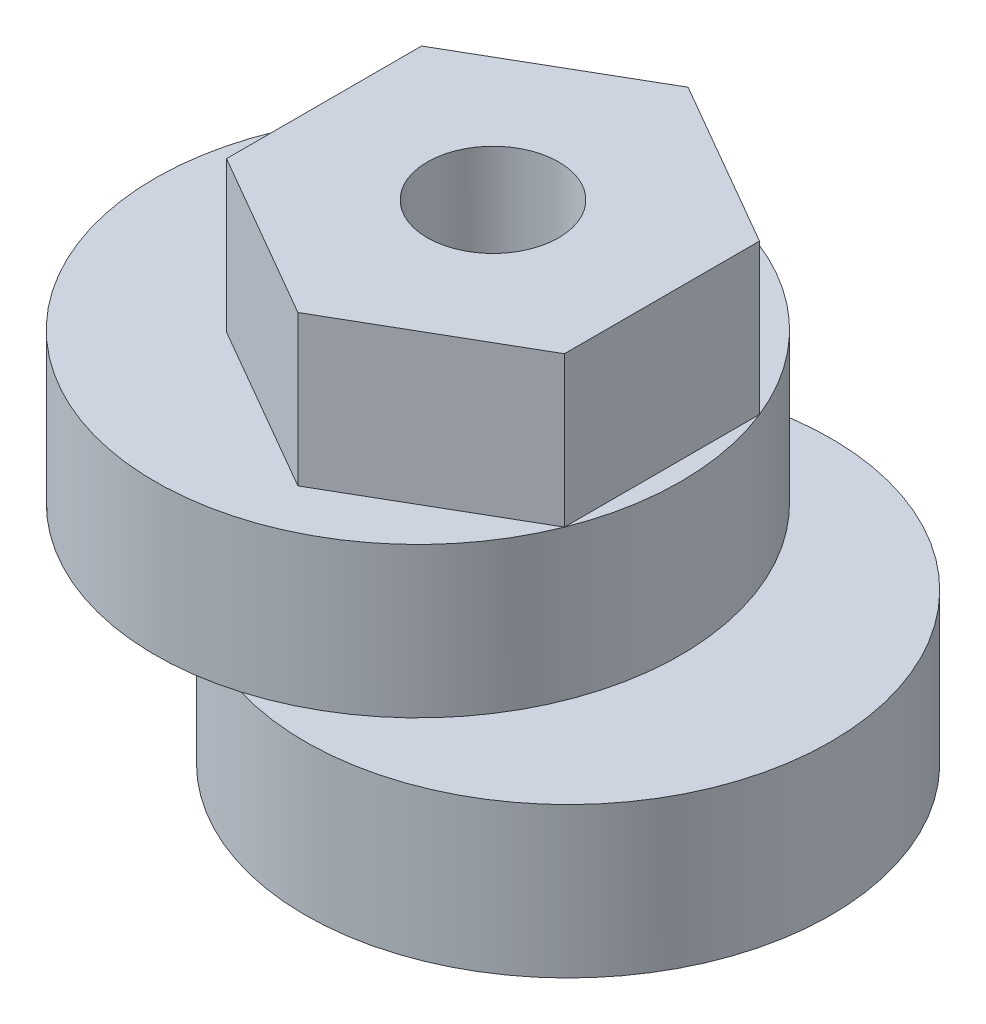
from build123d import *

# Parameters (mm, degrees)
SKETCH1_R           = 5
BOSS_EXTRUDE1_DEPTH = 2
SKETCH2_R           = 7
BOSS_EXTRUDE2_DEPTH = 4
SKETCH4_R           = 7
BOSS_EXTRUDE4_DEPTH = 4
SKETCH5_R           = 1.75
CUT_EXTRUDE1_DEPTH  = 11
SKETCH6_R           = 1.75
BOSS_EXTRUDE5_DEPTH = 4


with BuildPart() as part:
    # Sketch1 → Boss-Extrude1 (new body)
    with BuildSketch(Plane(origin=(0, 0, 0), x_dir=(1, 0, 0), z_dir=(0, 1, 0))):
        Circle(SKETCH1_R)
    extrude(amount=BOSS_EXTRUDE1_DEPTH)

    # Sketch2 → Boss-Extrude2 (add)
    with BuildSketch(Plane(origin=(0, 2, 0), x_dir=(1, 0, 0), z_dir=(0, 1, 0))):
        with Locations((2, 0)):
            Circle(SKETCH2_R)
    extrude(amount=BOSS_EXTRUDE2_DEPTH)

    # Sketch4 → Boss-Extrude4 (add)
    with BuildSketch(Plane(origin=(0, 6, 0), x_dir=(1, 0, 0), z_dir=(0, 1, 0))):
        with Locations((-2, 0)):
            Circle(SKETCH4_R)
    extrude(amount=BOSS_EXTRUDE4_DEPTH)

    # Sketch5 → Cut-Extrude1 (cut, through all)
    with BuildSketch(Plane.XZ):
        Circle(SKETCH5_R)
    extrude(amount=-CUT_EXTRUDE1_DEPTH, mode=Mode.SUBTRACT)

    # Sketch6 → Boss-Extrude5 (add)
    with BuildSketch(Plane(origin=(0, 10, 0), x_dir=(1, 0, 0), z_dir=(0, 1, 0))):
        Polygon((-4.5, 2.598076211), (-4.5, -2.598076211), (0, -5.196152423), (4.5, -2.598076211), (4.5, 2.598076211), (0, 5.196152423), align=None)
        Circle(SKETCH6_R, mode=Mode.SUBTRACT)
    extrude(amount=BOSS_EXTRUDE5_DEPTH)


solid = part.part
